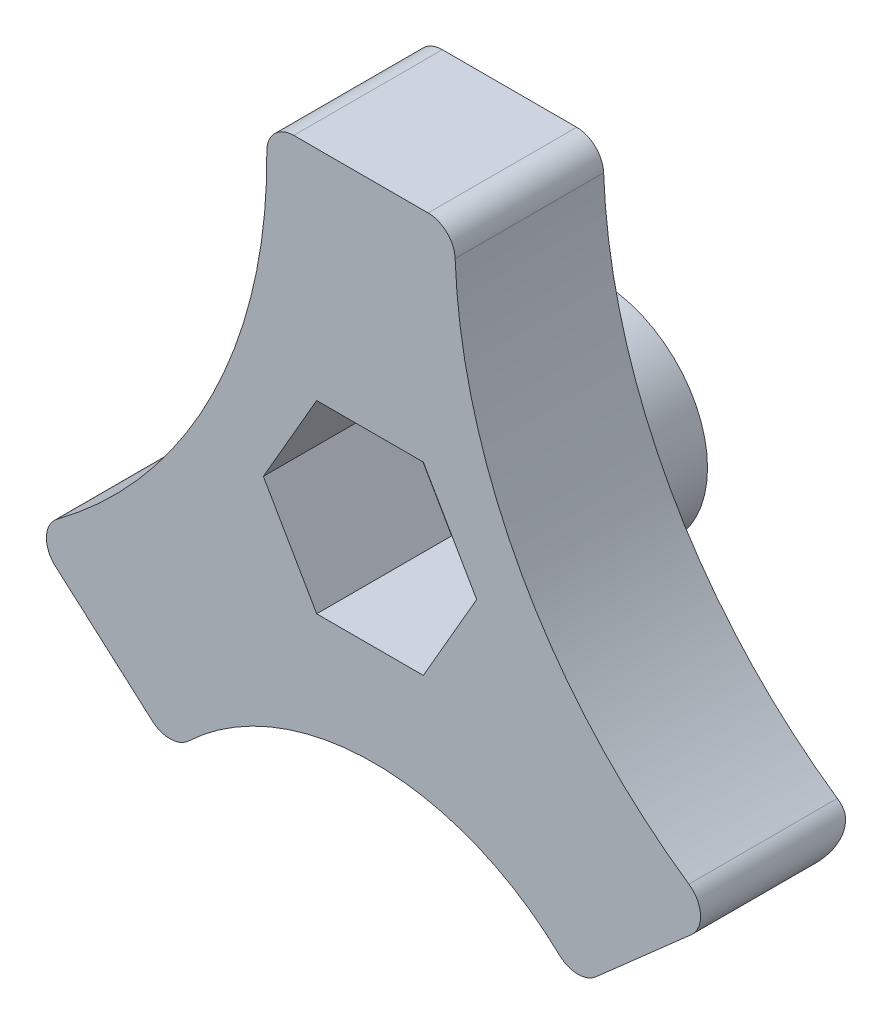
from build123d import *

# Parameters (mm, degrees)
BOSS_EXTRUDE1_DEPTH = 5.5
FILLET1_R           = 1
SKETCH2_R           = 4
BOSS_EXTRUDE2_DEPTH = 3
SKETCH3_R           = 1.75
CUT_EXTRUDE3_DEPTH  = 5
SKETCH4_R           = 1.75
CUT_EXTRUDE4_DEPTH  = 9.5000001


with BuildPart() as part:
    # Sketch1 → Boss-Extrude1 (new body)
    with BuildSketch(Plane.XY):
        with BuildLine():
            Line((-3.860140394, 18.642037645), (3.139859606, 18.642037645))
            ThreePointArc((3.139859606, 18.642037645), (5.695506545, 8.64046477), (12.898136912, 1.245540359))
            Line((12.898136912, 1.245540359), (7.648136912, -3.384524435))
            ThreePointArc((7.648136912, -3.384524435), (0.148136912, 0.001097287), (-7.351863088, -3.384524435))
            Line((-7.351863088, -3.384524435), (-12.601863088, 1.245540359))
            ThreePointArc((-12.601863088, 1.245540359), (-5.871247517, 8.758014837), (-3.860140394, 18.642037645))
        make_face()
    extrude(amount=BOSS_EXTRUDE1_DEPTH)

    # Fillet1
    fillet1_edges = [part.edges().sort_by_distance(p)[0] for p in [
        (-3.860140394, 18.642037645, 2.75),
        (3.139859606, 18.642037645, 2.75),
        (12.898136912, 1.245540359, 2.75),
        (7.648136912, -3.384524435, 2.75),
        (-7.351863088, -3.384524435, 2.75),
        (-12.601863088, 1.245540359, 2.75),
        (10.273136912, -1.069492038, 0),
    ]]
    fillet(fillet1_edges, radius=FILLET1_R)

    # Sketch2 → Boss-Extrude2 (add)
    with BuildSketch(Plane(origin=(0, 0, 0), x_dir=(-1, 0, 0), z_dir=(0, 0, -1))):
        with Locations((0, 7.142037645)):
            Circle(SKETCH2_R)
    extrude(amount=BOSS_EXTRUDE2_DEPTH)

    # Sketch3 → Cut-Extrude3 (cut)
    with BuildSketch(Plane.XY.offset(5.5)):
        Polygon((-3.95, 7.142037645), (-1.975, 3.7212373), (1.975, 3.7212373), (3.95, 7.142037645), (1.975, 10.56283799), (-1.975, 10.56283799), align=None)
        with Locations((0, 7.142037645)):
            Circle(SKETCH3_R, mode=Mode.SUBTRACT)
    extrude(amount=-CUT_EXTRUDE3_DEPTH, mode=Mode.SUBTRACT)

    # Sketch4 → Cut-Extrude4 (cut, through all)
    with BuildSketch(Plane(origin=(0, 0, -3), x_dir=(-1, 0, 0), z_dir=(0, 0, -1))):
        with Locations((0, 7.142037645)):
            Circle(SKETCH4_R)
    extrude(amount=-CUT_EXTRUDE4_DEPTH, mode=Mode.SUBTRACT)


solid = part.part
